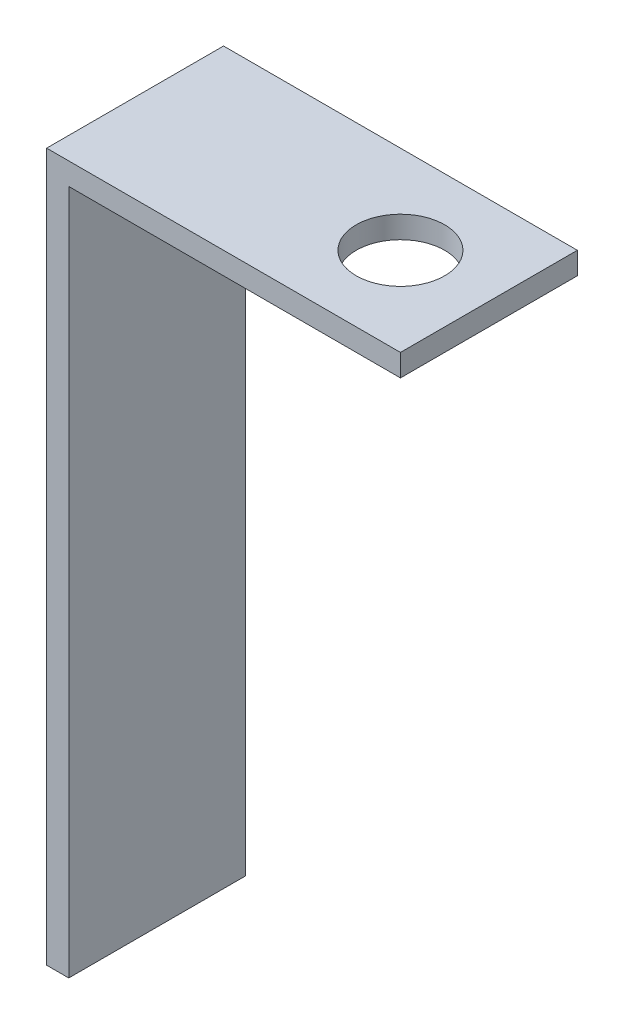
from build123d import *

# Parameters (mm, degrees)
EXTRUDE_THIN1_DEPTH = 12.7
SKETCH2_R           = 3.175
CUT_EXTRUDE1_DEPTH  = 10


with BuildPart() as part:
    # Sketch1 → Extrude-Thin1 (new body)
    with BuildSketch(Plane.XY):
        Polygon((0, 0), (0, 50.8), (25.4, 50.8), (25.4, 49.2125), (1.5875, 49.2125), (1.5875, 0), align=None)
    extrude(amount=EXTRUDE_THIN1_DEPTH)

    # Sketch2 → Cut-Extrude1 (cut)
    with BuildSketch(Plane(origin=(0, 50.8, 0), x_dir=(1, 0, 0), z_dir=(0, 1, 0))):
        with Locations((19.05, -6.35)):
            Circle(SKETCH2_R)
    extrude(amount=-CUT_EXTRUDE1_DEPTH, mode=Mode.SUBTRACT)


solid = part.part
